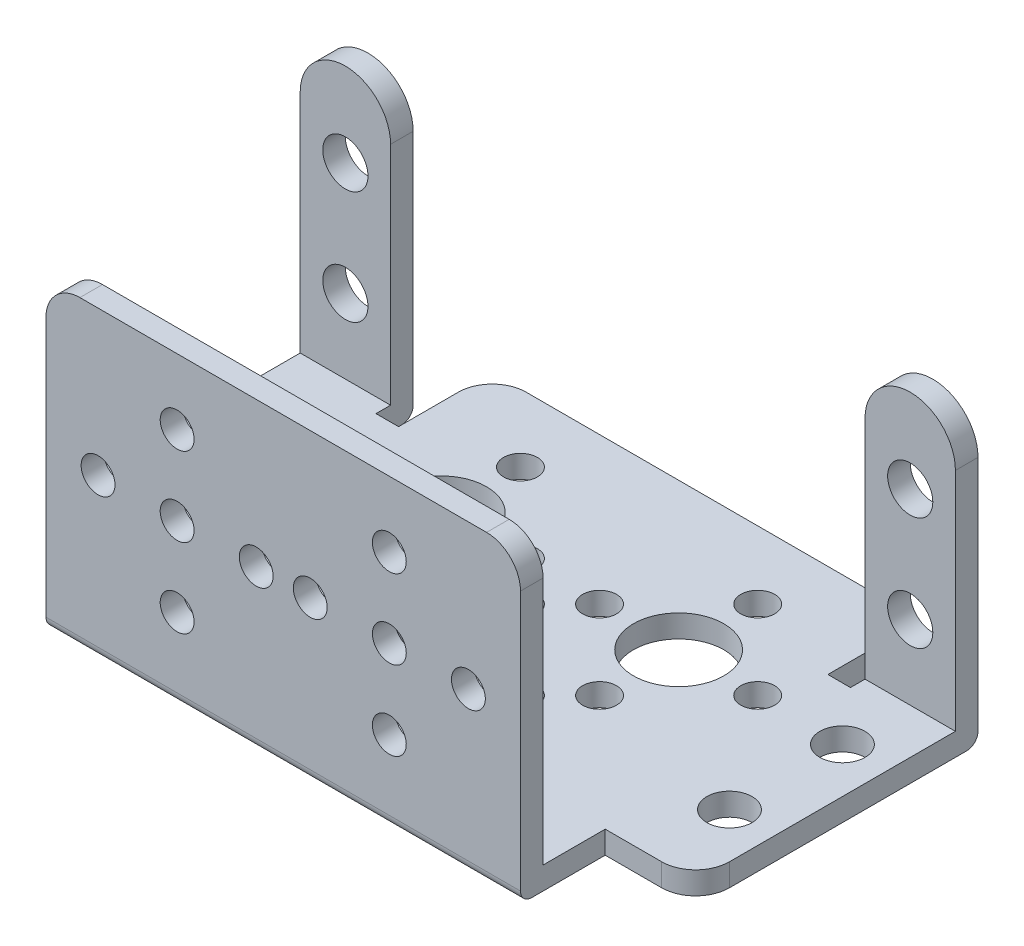
from build123d import *

# Parameters (mm, degrees)
SKETCH1_R               = 2
SKETCH1_R_2             = 4
SKETCH1_R_3             = 1.5
BOSS_EXTRUDE1_DEPTH     = 27
SKETCH3_W               = 28.5
SKETCH3_H               = 26.527175283
SKETCH3_W_2             = 6.268481117
CUT_EXTRUDE1_DEPTH      = 30
CUT_EXTRUDE1_DEPTH_BACK = 30
SKETCH4_R               = 2
SKETCH4_R_2             = 1.5
CUT_EXTRUDE2_DEPTH      = 38.5
SKETCH5_W               = 38
SKETCH5_H               = 27.064125823
CUT_EXTRUDE3_DEPTH      = 27
FILLET1_R               = 3
FILLET2_R               = 1


with BuildPart() as part:
    # Sketch1 → Boss-Extrude1 (new body)
    with BuildSketch(Plane(origin=(0, 0, 0), x_dir=(1, 0, 0), z_dir=(0, 1, 0))):
        with BuildLine():
            Line((21, 0), (-21, 0))
            Line((-21, 0), (-21, 7.5))
            Line((-21, 7.5), (-26, 7.5))
            ThreePointArc((-26, 7.5), (-28.121320344, 8.378679656), (-29, 10.5))
            Line((-29, 10.5), (-29, 32.5))
            Line((-29, 32.5), (-21, 32.5))
            Line((-21, 32.5), (-21, 29.209337349))
            Line((-21, 29.209337349), (-19, 29.209337349))
            Line((-19, 29.209337349), (-19, 34.5))
            ThreePointArc((-19, 34.5), (-18.121320344, 36.621320344), (-16, 37.5))
            Line((-16, 37.5), (16, 37.5))
            ThreePointArc((16, 37.5), (18.121320344, 36.621320344), (19, 34.5))
            Line((19, 34.5), (19, 29.209337349))
            Line((19, 29.209337349), (21, 29.209337349))
            Line((21, 29.209337349), (21, 32.5))
            Line((21, 32.5), (29, 32.5))
            Line((29, 32.5), (29, 10.5))
            ThreePointArc((29, 10.5), (28.121320344, 8.378679656), (26, 7.5))
            Line((26, 7.5), (21, 7.5))
            Line((21, 7.5), (21, 0))
        make_face()
        with Locations((-25, 24.5)):
            Circle(SKETCH1_R, mode=Mode.SUBTRACT)
        with Locations((-25, 14.5)):
            Circle(SKETCH1_R, mode=Mode.SUBTRACT)
        with Locations((25, 14.5)):
            Circle(SKETCH1_R, mode=Mode.SUBTRACT)
        with Locations((25, 24.5)):
            Circle(SKETCH1_R, mode=Mode.SUBTRACT)
        with Locations((0, 14)):
            Circle(SKETCH1_R_2, mode=Mode.SUBTRACT)
        with Locations((0, 21)):
            Circle(SKETCH1_R_3, mode=Mode.SUBTRACT)
        with Locations((7, 14)):
            Circle(SKETCH1_R_3, mode=Mode.SUBTRACT)
        with Locations((0, 7)):
            Circle(SKETCH1_R_3, mode=Mode.SUBTRACT)
        with Locations((-7, 14)):
            Circle(SKETCH1_R_3, mode=Mode.SUBTRACT)
        with Locations((10.5, 24.5)):
            Circle(SKETCH1_R_2, mode=Mode.SUBTRACT)
        with Locations((10.5, 31.5)):
            Circle(SKETCH1_R_3, mode=Mode.SUBTRACT)
        with Locations((-10.5, 24.5)):
            Circle(SKETCH1_R_2, mode=Mode.SUBTRACT)
        with Locations((-10.5, 31.5)):
            Circle(SKETCH1_R_3, mode=Mode.SUBTRACT)
        with Locations((3.5, 24.5)):
            Circle(SKETCH1_R_3, mode=Mode.SUBTRACT)
        with Locations((10.5, 17.5)):
            Circle(SKETCH1_R_3, mode=Mode.SUBTRACT)
        with Locations((17.5, 24.5)):
            Circle(SKETCH1_R_3, mode=Mode.SUBTRACT)
        with Locations((-3.5, 24.5)):
            Circle(SKETCH1_R_3, mode=Mode.SUBTRACT)
        with Locations((-10.5, 17.5)):
            Circle(SKETCH1_R_3, mode=Mode.SUBTRACT)
        with Locations((-17.5, 24.5)):
            Circle(SKETCH1_R_3, mode=Mode.SUBTRACT)
    extrude(amount=BOSS_EXTRUDE1_DEPTH)

    # Sketch3 → Cut-Extrude1 (cut, two sides)
    with BuildSketch(Plane(origin=(0, 0, 0), x_dir=(0, 0, -1), z_dir=(1, 0, 0))) as cut_extrude1_sk:
        with Locations((16.25, 15.263587642)):
            Rectangle(SKETCH3_W, SKETCH3_H)
        with Locations((35.691254192, 15.263587642)):
            Rectangle(SKETCH3_W_2, SKETCH3_H)
    extrude(amount=CUT_EXTRUDE1_DEPTH, mode=Mode.SUBTRACT)
    extrude(cut_extrude1_sk.sketch, amount=-CUT_EXTRUDE1_DEPTH_BACK, mode=Mode.SUBTRACT)

    # Sketch4 → Cut-Extrude2 (cut, through all)
    with BuildSketch(Plane.XY):
        with Locations((-25, 18.573417332)):
            Circle(SKETCH4_R)
        with Locations((-25, 8.573417332)):
            Circle(SKETCH4_R)
        with Locations((-9.391233077, 21.187393838)):
            Circle(SKETCH4_R_2)
        with Locations((-2.391233077, 14.187393838)):
            Circle(SKETCH4_R_2)
        with Locations((-9.391233077, 7.187393838)):
            Circle(SKETCH4_R_2)
        with Locations((-16.391233077, 14.187393838)):
            Circle(SKETCH4_R_2)
        with Locations((2.391233077, 14.187393838)):
            Circle(SKETCH4_R_2)
        with Locations((16.391233077, 14.187393838)):
            Circle(SKETCH4_R_2)
        with Locations((9.391233077, 7.187393838)):
            Circle(SKETCH4_R_2)
        with Locations((9.391233077, 21.187393838)):
            Circle(SKETCH4_R_2)
        with Locations((25, 8.573417332)):
            Circle(SKETCH4_R)
        with Locations((25, 18.573417332)):
            Circle(SKETCH4_R)
        with Locations((-9.391233077, 14.187393838)):
            Circle(SKETCH4_R_2)
        with Locations((9.391233077, 14.187393838)):
            Circle(SKETCH4_R_2)
        with BuildLine():
            Line((-29, 22), (-29, 28.587976658))
            Line((-29, 28.587976658), (-21, 28.587976658))
            Line((-21, 28.587976658), (-21, 22))
            ThreePointArc((-21, 22), (-25, 26), (-29, 22))
        make_face()
        with BuildLine():
            Line((21, 28.587976658), (21, 22))
            ThreePointArc((21, 22), (25, 26), (29, 22))
            Line((29, 22), (29, 28.587976658))
            Line((29, 28.587976658), (21, 28.587976658))
        make_face()
    extrude(amount=-CUT_EXTRUDE2_DEPTH, mode=Mode.SUBTRACT)

    # Sketch5 → Cut-Extrude3 (cut)
    with BuildSketch(Plane(origin=(0, 0, -32.557013634), x_dir=(-1, 0, 0), z_dir=(0, 0, -1))):
        with Locations((0, 15.532062912)):
            Rectangle(SKETCH5_W, SKETCH5_H)
    extrude(amount=-CUT_EXTRUDE3_DEPTH, mode=Mode.SUBTRACT)

    # Fillet1
    fillet1_edges = [part.edges().sort_by_distance(p)[0] for p in [
        (21, 27, -1),
        (-21, 27, -1),
    ]]
    fillet(fillet1_edges, radius=FILLET1_R)

    # Fillet2
    fillet2_edges = [part.edges().sort_by_distance(p)[0] for p in [
        (-25, 0, -32.5),
        (25, 0, -32.5),
        (0, 0, 0),
    ]]
    fillet(fillet2_edges, radius=FILLET2_R)


solid = part.part
